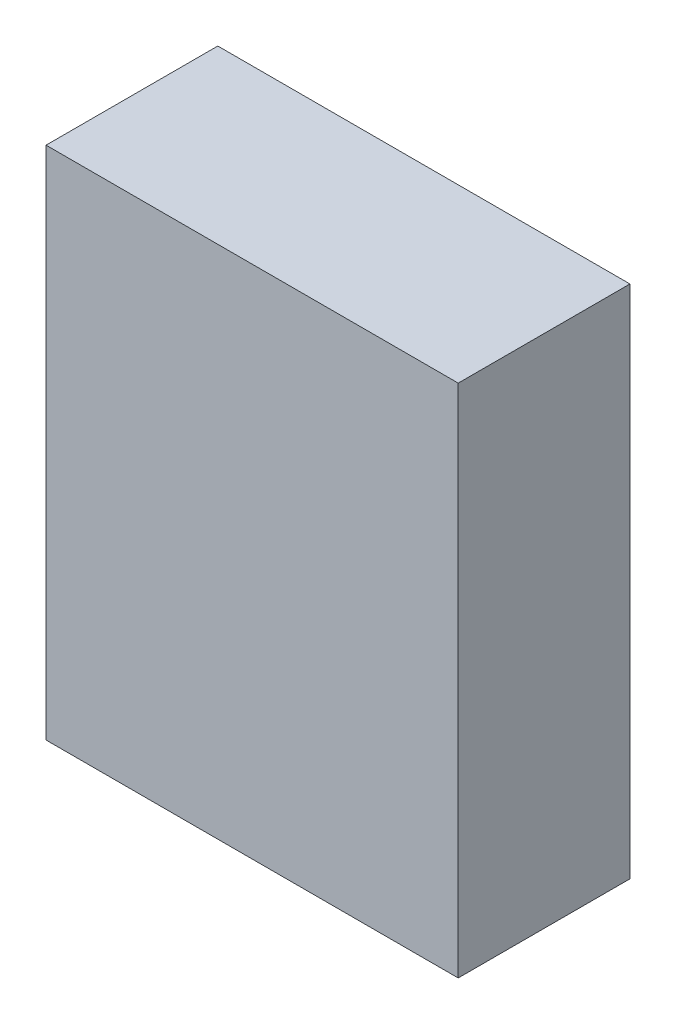
from build123d import *

# Parameters (mm, degrees)
SKETCH_1_W      = 60
SKETCH_1_H      = 75
EXTRUDE_1_DEPTH = 25


with BuildPart() as part:
    # 草图1 → 凸台-拉伸1 (new body)
    with BuildSketch(Plane.XY):
        Rectangle(SKETCH_1_W, SKETCH_1_H)
    extrude(amount=EXTRUDE_1_DEPTH)


solid = part.part
